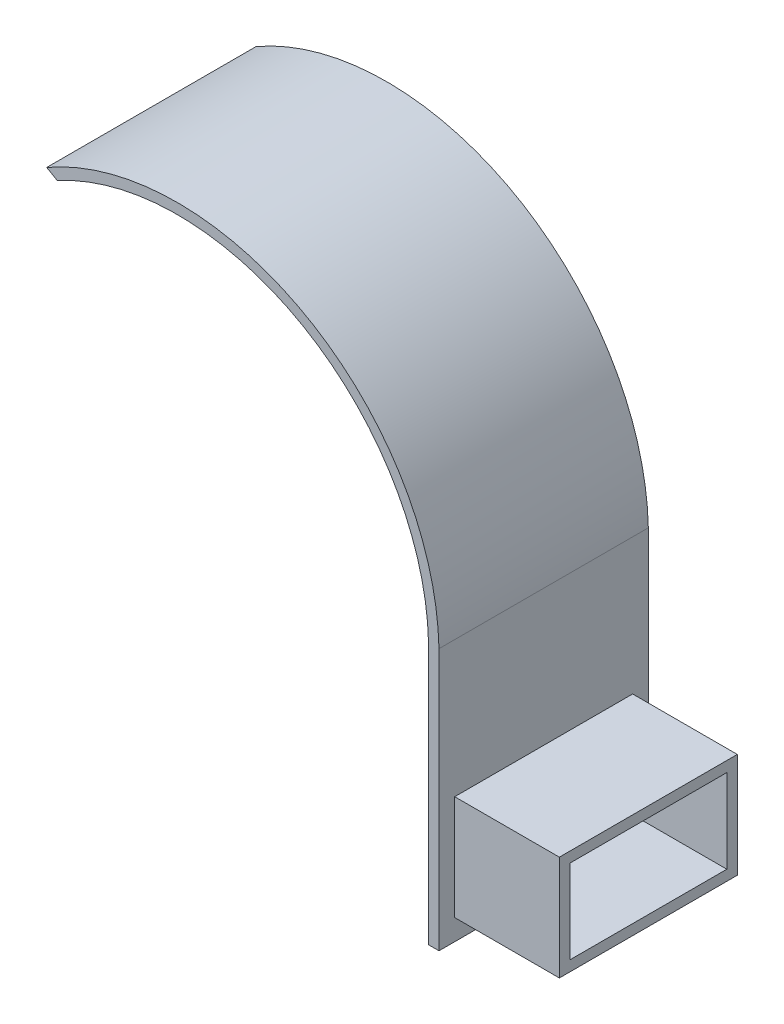
from build123d import *

# Parameters (mm, degrees)
SKETCH2_R           = 25
SKETCH2_R_2         = 24
BOSS_EXTRUDE1_DEPTH = 20
CUT_EXTRUDE1_DEPTH  = 21
SKETCH4_W           = 1.280900959
SKETCH4_H           = 0.727497166
CUT_EXTRUDE2_DEPTH  = 21
SKETCH5_W           = 1.000282178
SKETCH5_H           = 20
BOSS_EXTRUDE2_DEPTH = 25
SKETCH6_W           = 15
SKETCH6_H           = 8
CUT_EXTRUDE3_DEPTH  = 38.481628733
SKETCH7_W           = 17
SKETCH7_H           = 10
SKETCH7_W_2         = 15
SKETCH7_H_2         = 8
BOSS_EXTRUDE3_DEPTH = 10


with BuildPart() as part:
    # Sketch2 → Boss-Extrude1 (new body)
    with BuildSketch(Plane.XY):
        Circle(SKETCH2_R)
        Circle(SKETCH2_R_2, mode=Mode.SUBTRACT)
    extrude(amount=BOSS_EXTRUDE1_DEPTH)

    # Sketch3 → Cut-Extrude1 (cut, through all)
    with BuildSketch(Plane.XY.offset(20)):
        Polygon((-12.48839905, 21.657328764), (25, 0), (47.90060784, -51.20755357), (-94.197848054, -17.737254368), align=None)
    extrude(amount=-CUT_EXTRUDE1_DEPTH, mode=Mode.SUBTRACT)

    # Sketch4 → Cut-Extrude2 (cut, through all)
    with BuildSketch(Plane.XY.offset(20)):
        with Locations((24.633397985, 0.218033182)):
            Rectangle(SKETCH4_W, SKETCH4_H)
    extrude(amount=-CUT_EXTRUDE2_DEPTH, mode=Mode.SUBTRACT)

    # Sketch5 → Boss-Extrude2 (add)
    with BuildSketch(Plane.XZ.offset(-0.581781765)):
        with Locations((24.493088594, 10)):
            Rectangle(SKETCH5_W, SKETCH5_H)
    extrude(amount=BOSS_EXTRUDE2_DEPTH)

    # Sketch6 → Cut-Extrude3 (cut, through all)
    with BuildSketch(Plane(origin=(24.993229683, 0, 0), x_dir=(0, 0, -1), z_dir=(1, 0, 0))):
        with Locations((-10, -17.418218235)):
            Rectangle(SKETCH6_W, SKETCH6_H)
    extrude(amount=-CUT_EXTRUDE3_DEPTH, mode=Mode.SUBTRACT)

    # Sketch7 → Boss-Extrude3 (add)
    with BuildSketch(Plane(origin=(24.993229683, 0, 0), x_dir=(0, 0, -1), z_dir=(1, 0, 0))):
        with Locations((-10, -17.418218235)):
            Rectangle(SKETCH7_W, SKETCH7_H)
        with Locations((-10, -17.418218235)):
            Rectangle(SKETCH7_W_2, SKETCH7_H_2, mode=Mode.SUBTRACT)
    extrude(amount=BOSS_EXTRUDE3_DEPTH)


solid = part.part
